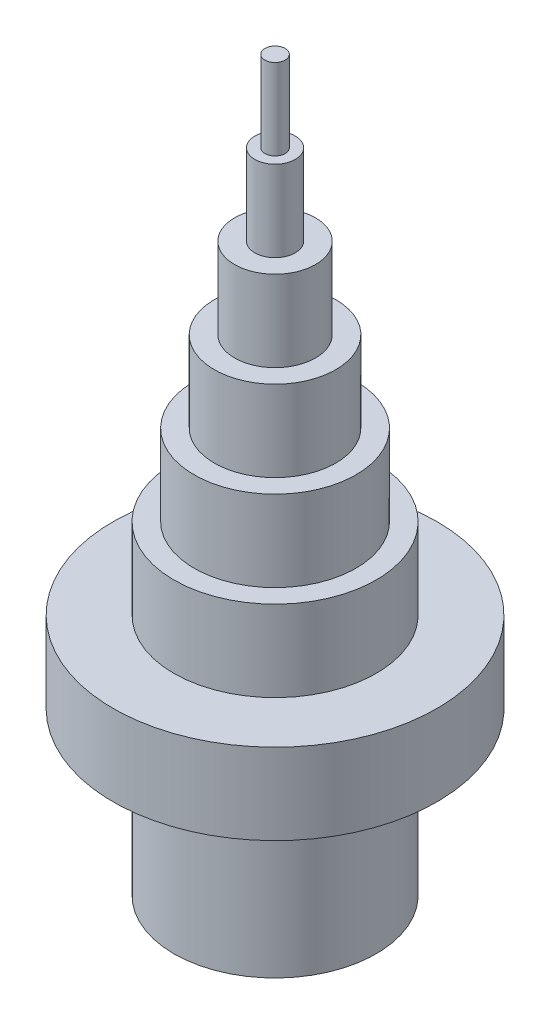
from build123d import *

# Parameters (mm, degrees)
SKETCH2_R          = 20
CUT_EXTRUDE1_DEPTH = 40


with BuildPart() as part:
    # Sketch1 → Revolve1 (revolve)
    with BuildSketch(Plane.XY, mode=Mode.PRIVATE) as revolve1_sk:
        Polygon((0, 0), (25, 0), (25, 40), (40, 40), (40, 60), (25, 60), (25, 80), (20, 80), (20, 100), (15, 100), (15, 120), (10, 120), (10, 140), (5, 140), (5, 160), (2.5, 160), (2.5, 180), (0, 180), align=None)
    revolve(revolve1_sk.sketch.rotate(Axis((0, 0, 0), (0, 1, 0)), 90), axis=Axis((0, 0, 0), (0, 1, 0)))  # turned: the seam where the file's is

    # Sketch2 → Cut-Extrude1 (cut)
    with BuildSketch(Plane.XZ):
        with Locations(Location((0, 0, 0), (0, 0, 270))):  # turned: the seam where the file's is
            Circle(SKETCH2_R)
    extrude(amount=-CUT_EXTRUDE1_DEPTH, mode=Mode.SUBTRACT)


solid = part.part
